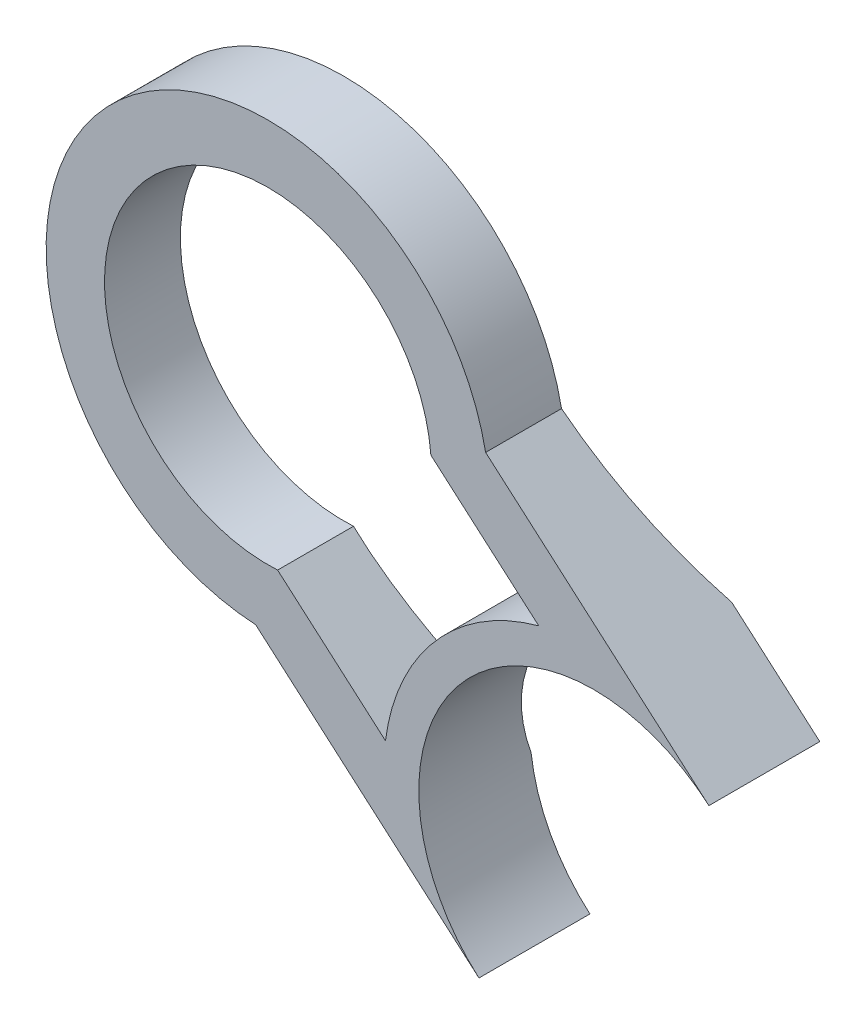
from build123d import *

# Parameters (mm, degrees)
BOSS_EXTRUDE1_DEPTH     = 19
CUT_EXTRUDE1_DEPTH      = 49.249947637
CUT_EXTRUDE1_DEPTH_BACK = 109.67350832


with BuildPart() as part:
    # Sketch1 → Boss-Extrude1 (new body)
    with BuildSketch(Plane.XY):
        with BuildLine():
            Line((-265.157990376, 195.999066862), (-226.911895103, 162.718581948))
            ThreePointArc((-226.911895103, 162.718581948), (-269.236431055, 159.780273509), (-266.298122616, 117.455737558))
            Line((-266.298122616, 117.455737558), (-304.54421789, 150.736222472))
            ThreePointArc((-304.54421789, 150.736222472), (-331.112603464, 213.622868622), (-265.157990376, 195.999066862))
        make_face()
        with BuildLine():
            Line((-300.79209478, 160.727155027), (-282.314825505, 144.648847504))
            ThreePointArc((-282.314825505, 144.648847504), (-273.762715494, 163.71889626), (-256.057340496, 174.824077098))
            Line((-256.057340496, 174.824077098), (-274.534609771, 190.902384621))
            ThreePointArc((-274.534609771, 190.902384621), (-323.568796066, 207.05849737), (-300.79209478, 160.727155027))
        make_face(mode=Mode.SUBTRACT)
    extrude(amount=BOSS_EXTRUDE1_DEPTH)

    # Sketch2 → Cut-Extrude1 (cut, two sides)
    with BuildSketch(Plane(origin=(-17.199721271, -19.766003413, 0), x_dir=(0.75438074, -0.656437125, 0), z_dir=(0.656437125, 0.75438074, 0))) as cut_extrude1_sk:
        with BuildLine():
            Line((-407.026362297, 14.142127452), (-297.992481459, 14.142127452))
            Line((-297.992481459, 14.142127452), (-297.992481459, 0))
            ThreePointArc((-297.992481459, 0), (-313.1180692, -4.209672376), (-328.716129113, -6))
            Line((-328.716129113, -6), (-407.026362297, -6))
            Line((-407.026362297, -6), (-407.026362297, 14.142127452))
        make_face()
    extrude(amount=CUT_EXTRUDE1_DEPTH, mode=Mode.SUBTRACT)
    extrude(cut_extrude1_sk.sketch, amount=-CUT_EXTRUDE1_DEPTH_BACK, mode=Mode.SUBTRACT)


solid = part.part
